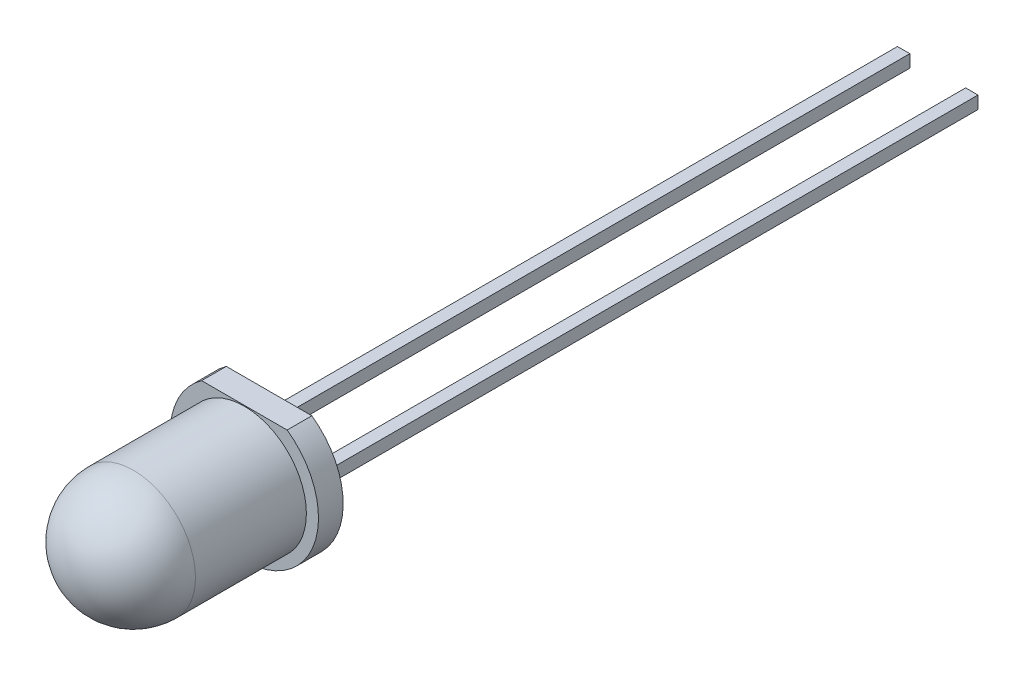
from build123d import *

# Parameters (mm, degrees)
BOSS_EXTRUDE2_DEPTH = 1
SKETCH2_W           = 0.5
SKETCH2_H           = 0.51
BOSS_EXTRUDE3_DEPTH = 25.69
SKETCH4_W           = 0.5
SKETCH4_H           = 0.51
BOSS_EXTRUDE4_DEPTH = 2.76
SKETCH5_R           = 2.51
BOSS_EXTRUDE5_DEPTH = 7
FILLET2_R           = 2.51


with BuildPart() as part:
    # Sketch1 → Boss-Extrude2 (new body)
    with BuildSketch(Plane.XY):
        with BuildLine():
            Line((-1.731328969, 2.45), (1.731328969, 2.45))
            ThreePointArc((1.731328969, 2.45), (0, -3), (-1.731328969, 2.45))
        make_face()
    extrude(amount=BOSS_EXTRUDE2_DEPTH)

    # Sketch2 → Boss-Extrude3 (add)
    with BuildSketch(Plane(origin=(0, 0, 0), x_dir=(-1, 0, 0), z_dir=(0, 0, -1))):
        with Locations((0, 1.305)):
            Rectangle(SKETCH2_W, SKETCH2_H)
        with Locations((0, -1.525)):
            Rectangle(SKETCH2_W, SKETCH2_H)
    extrude(amount=BOSS_EXTRUDE3_DEPTH)

    # Sketch4 → Boss-Extrude4 (add)
    with BuildSketch(Plane(origin=(0, 0, -25.69), x_dir=(-1, 0, 0), z_dir=(0, 0, -1))):
        with Locations((0, -1.525)):
            Rectangle(SKETCH4_W, SKETCH4_H)
    extrude(amount=BOSS_EXTRUDE4_DEPTH)

    # Sketch5 → Boss-Extrude5 (add)
    with BuildSketch(Plane.XY.offset(1)):
        with Locations((0, -0.09)):
            Circle(SKETCH5_R)
    extrude(amount=BOSS_EXTRUDE5_DEPTH)

    # Fillet2
    fillet2_edges = [part.edges().sort_by_distance(p)[0] for p in [
        (-2.51, -0.09, 8),
    ]]
    fillet(fillet2_edges, radius=FILLET2_R)


solid = part.part
